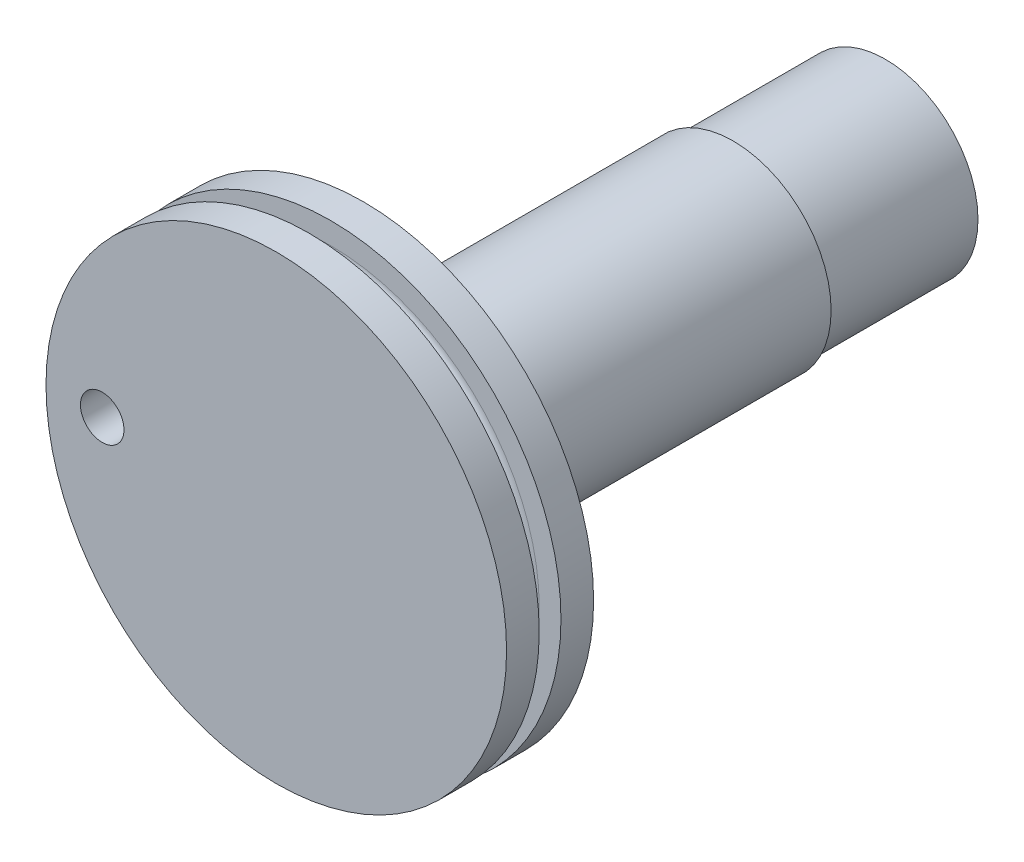
from build123d import *

# Parameters (mm, degrees)
SKETCH1_R           = 4.25
BOSS_EXTRUDE1_DEPTH = 7
SKETCH2_R           = 4.5
BOSS_EXTRUDE2_DEPTH = 21
SKETCH3_R           = 10.583681917
BOSS_EXTRUDE3_DEPTH = 4
SKETCH8_R           = 1
CUT_EXTRUDE1_DEPTH  = 4


with BuildPart() as part:
    # Sketch1 → Boss-Extrude1 (new body)
    with BuildSketch(Plane.XY):
        with Locations((21, 71.5)):
            Circle(SKETCH1_R)
    extrude(amount=BOSS_EXTRUDE1_DEPTH)

    # Sketch2 → Boss-Extrude2 (add)
    with BuildSketch(Plane.XY.offset(7)):
        with Locations((21, 71.5)):
            Circle(SKETCH2_R)
    extrude(amount=BOSS_EXTRUDE2_DEPTH)

    # Sketch3 → Boss-Extrude3 (add)
    with BuildSketch(Plane.XY.offset(28)):
        with Locations((21, 71.5)):
            Circle(SKETCH3_R)
    extrude(amount=-BOSS_EXTRUDE3_DEPTH)

    # Sketch6 → Cut-Revolve1 (revolve, cut)
    with BuildSketch(Plane(origin=(0, 71.5, 0), x_dir=(1, 0, 0), z_dir=(0, 1, 0))):
        with BuildLine():
            Line((31.583681917, -26.5), (31.583681917, -25.5))
            Line((31.583681917, -25.5), (30.583681917, -25.5))
            ThreePointArc((30.583681917, -25.5), (30.083681917, -26), (30.583681917, -26.5))
            Line((30.583681917, -26.5), (31.583681917, -26.5))
        make_face()
    revolve(axis=Axis((21, 71.5, 28), (0, 0, -1)), mode=Mode.SUBTRACT)

    # Sketch8 → Cut-Extrude1 (cut)
    with BuildSketch(Plane(origin=(0, 0, 24), x_dir=(-1, 0, 0), z_dir=(0, 0, -1))):
        with Locations((-13, 71.5)):
            Circle(SKETCH8_R)
    extrude(amount=-CUT_EXTRUDE1_DEPTH, mode=Mode.SUBTRACT)


solid = part.part
